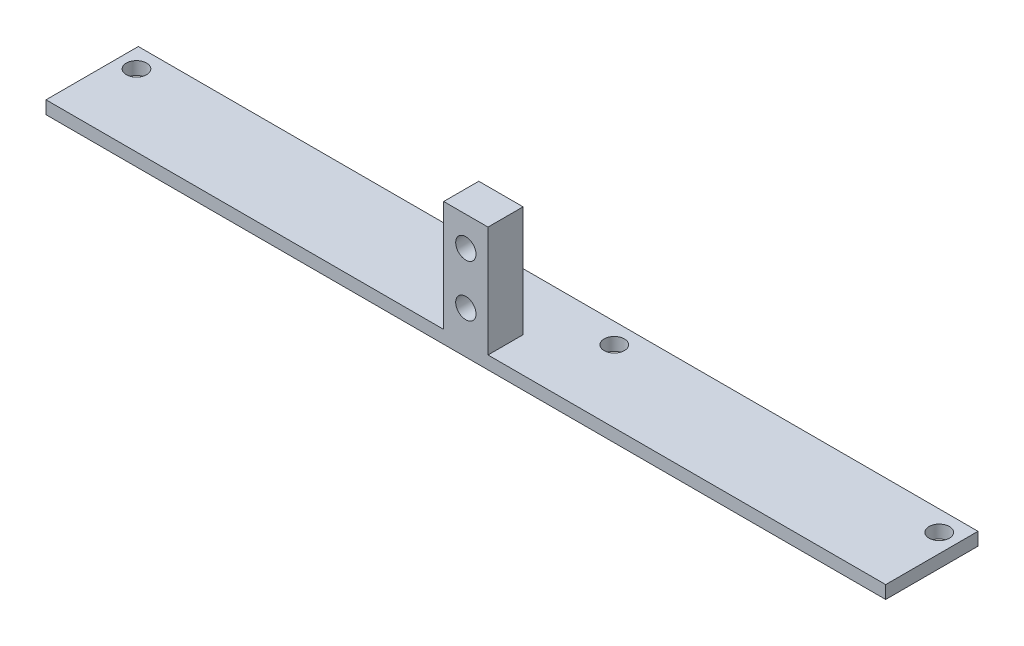
from build123d import *

# Parameters (mm, degrees)
SKETCH2_W                        = 114.7
SKETCH2_H                        = 12.5
BRACKETBASE_DEPTH                = 1.75
SKETCH3_R                        = 1.375
BOTTOMCHASSISMOUNTINGHOLES_DEPTH = 1.75
SKETCH4_W                        = 6
SKETCH4_H                        = 16.75
MOUNTINGTABS_DEPTH               = 4.75
SKETCH5_W                        = 6
SKETCH5_H                        = 1.75
EXTENSION_DEPTH                  = 7.75
SKETCH6_R                        = 1.375
REARSHELLMOUNTINGHOLES_DEPTH     = 4.75
SKETCH8_R                        = 3.25
CUT_EXTRUDE2_DEPTH               = 10
SKETCH9_R                        = 3.25
CUT_EXTRUDE3_DEPTH               = 10
SKETCH10_W                       = 6.5
SKETCH10_H                       = 12.5
CUT_EXTRUDE4_DEPTH               = 16
CUT_EXTRUDE4_DEPTH_BACK          = 2.75


with BuildPart() as part:
    # Sketch2 → bracketBase (new body)
    with BuildSketch(Plane(origin=(0, 0, 0), x_dir=(1, 0, 0), z_dir=(0, 1, 0))):
        with Locations((57.35, 6.25)):
            Rectangle(SKETCH2_W, SKETCH2_H)
    extrude(amount=BRACKETBASE_DEPTH)

    # Sketch3 → bottomChassisMountingHoles (cut)
    with BuildSketch(Plane(origin=(0, 1.75, 0), x_dir=(1, 0, 0), z_dir=(0, 1, 0))):
        with Locations((3, 9.75)):
            Circle(SKETCH3_R)
        with Locations((47, 9.75)):
            Circle(SKETCH3_R)
        with Locations((67.7, 9.75)):
            Circle(SKETCH3_R)
        with Locations((111.7, 9.75)):
            Circle(SKETCH3_R)
    extrude(amount=-BOTTOMCHASSISMOUNTINGHOLES_DEPTH, mode=Mode.SUBTRACT)

    # Sketch4 → mountingTabs (add)
    with BuildSketch(Plane.XY):
        with Locations((117.7, 8.375)):
            Rectangle(SKETCH4_W, SKETCH4_H)
        with Locations((-3, 8.375)):
            Rectangle(SKETCH4_W, SKETCH4_H)
        with Locations((57.35, 8.375)):
            Rectangle(SKETCH4_W, SKETCH4_H)
    extrude(amount=-MOUNTINGTABS_DEPTH)

    # Sketch5 → extension (add)
    with BuildSketch(Plane(origin=(0, 0, -12.5), x_dir=(-1, 0, 0), z_dir=(0, 0, -1))):
        with Locations((-117.7, 0.875)):
            Rectangle(SKETCH5_W, SKETCH5_H)
        with Locations((3, 0.875)):
            Rectangle(SKETCH5_W, SKETCH5_H)
    extrude(amount=-EXTENSION_DEPTH)

    # Sketch6 → rearShellMountingHoles (cut)
    with BuildSketch(Plane(origin=(0, 0, -4.75), x_dir=(-1, 0, 0), z_dir=(0, 0, -1))):
        with Locations((-57.35, 12.75)):
            Circle(SKETCH6_R)
        with Locations((-57.35, 5.75)):
            Circle(SKETCH6_R)
        with Locations((-117.7, 12.75)):
            Circle(SKETCH6_R)
        with Locations((-117.7, 5.75)):
            Circle(SKETCH6_R)
        with Locations((3, 5.75)):
            Circle(SKETCH6_R)
        with Locations((3, 12.75)):
            Circle(SKETCH6_R)
    extrude(amount=-REARSHELLMOUNTINGHOLES_DEPTH, mode=Mode.SUBTRACT)

    # Sketch8 → Cut-Extrude2 (cut)
    with BuildSketch(Plane(origin=(0, 1.75, 0), x_dir=(1, 0, 0), z_dir=(0, 1, 0))):
        with Locations((120.95, 8.5675)):
            Circle(SKETCH8_R)
        with Locations((-6.25, 8.5675)):
            Circle(SKETCH8_R)
    extrude(amount=-CUT_EXTRUDE2_DEPTH, mode=Mode.SUBTRACT)

    # Sketch9 → Cut-Extrude3 (cut)
    with BuildSketch(Plane.XZ.offset(-1.75)):
        with Locations((-6.25, -8.5675)):
            Circle(SKETCH9_R)
        with BuildLine():
            Line((120.7, -5.327129651), (122.422971605, -5.194199506))
            Line((122.422971605, -5.194199506), (122.933227388, -11.807870349))
            Line((122.933227388, -11.807870349), (120.7, -11.807870349))
            ThreePointArc((120.7, -11.807870349), (117.7, -8.5675), (120.7, -5.327129651))
        make_face()
    extrude(amount=-CUT_EXTRUDE3_DEPTH, mode=Mode.SUBTRACT)

    # Sketch10 → Cut-Extrude4 (cut, two sides)
    with BuildSketch(Plane(origin=(0, 1.75, 0), x_dir=(1, 0, 0), z_dir=(0, 1, 0))) as cut_extrude4_sk:
        with Locations((117.45, 6.25)):
            Rectangle(SKETCH10_W, SKETCH10_H)
        with Locations((-2.75, 6.25)):
            Rectangle(SKETCH10_W, SKETCH10_H)
    extrude(amount=CUT_EXTRUDE4_DEPTH, mode=Mode.SUBTRACT)
    extrude(cut_extrude4_sk.sketch, amount=-CUT_EXTRUDE4_DEPTH_BACK, mode=Mode.SUBTRACT)


solid = part.part
